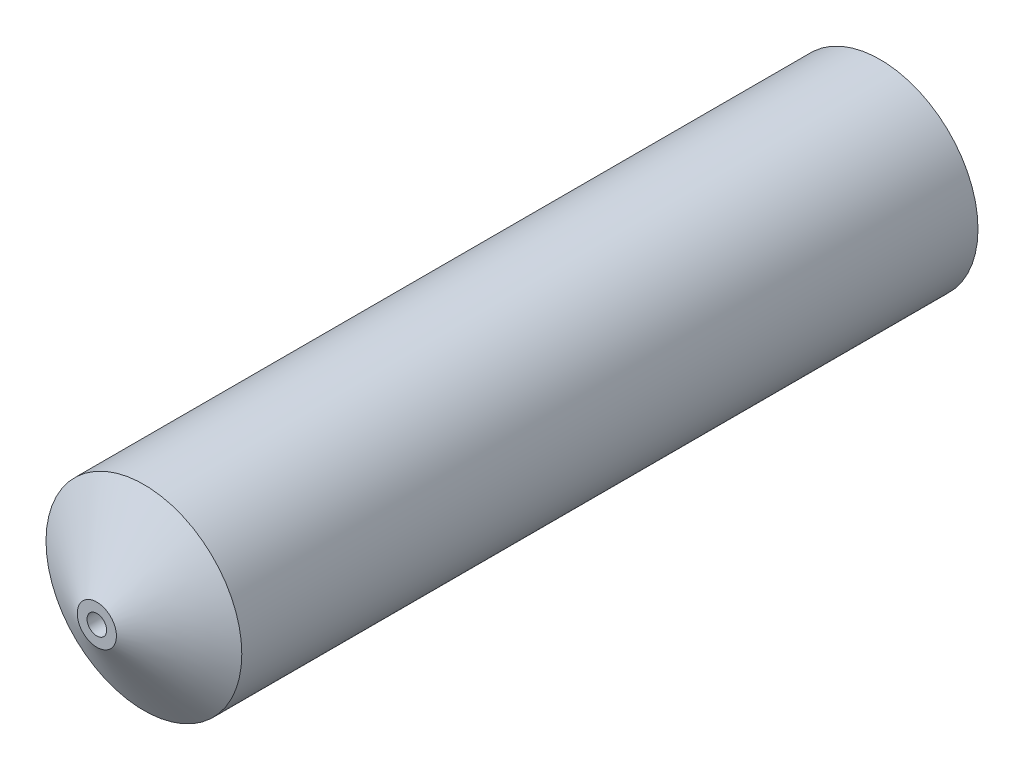
from build123d import *


with BuildPart() as part:
    # Sketch1 → Revolve1 (revolve)
    with BuildSketch(Plane(origin=(0, 0, 0), x_dir=(1, 0, 0), z_dir=(0, 1, 0))):
        Polygon((0.25, -20), (0.5, -20), (2.5, -18.798278762), (2.5, 0), (1.65, 0), (1.65, -4), (1, -4), (1, -18.949354536), (0.25, -19.4), align=None)
    revolve(axis=Axis((0, 0, 0), (0, 0, 1)))


solid = part.part
